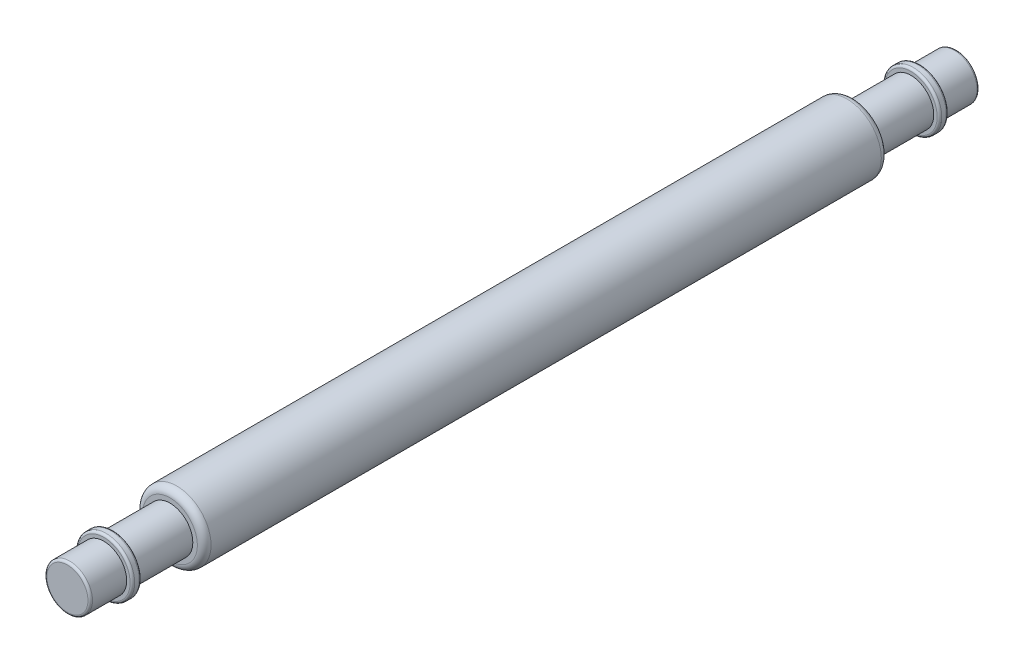
from build123d import *

# Parameters (mm, degrees)
SKETCH1_R            = 0.75
BOSS_EXTRUDE1_DEPTH  = 7.5
SKETCH2_R            = 0.5
BOSS_EXTRUDE2_DEPTH  = 9.75
FILLET1_R            = 0.15
FILLET2_R            = 0.05
BOSS_EXTRUDE3_START  = -0.8
SKETCH3_R            = 0.625
BOSS_EXTRUDE3_DEPTH  = 0.2
FILLET3_R            = 0.05
FILLET3_OF_MIRROR1_R = 0.05


with BuildPart() as part:
    # Sketch1 → Boss-Extrude1 (new body, symmetric)
    with BuildSketch(Plane.XY):
        Circle(SKETCH1_R)
    extrude(amount=BOSS_EXTRUDE1_DEPTH, both=True)

    # Sketch2 → Boss-Extrude2 (add, symmetric)
    with BuildSketch(Plane.XY):
        Circle(SKETCH2_R)
    extrude(amount=BOSS_EXTRUDE2_DEPTH, both=True)

    # Fillet1
    fillet1_edges = [part.edges().sort_by_distance(p)[0] for p in [
        (-0.75, 0, -7.5),
        (-0.75, 0, 7.5),
    ]]
    fillet(fillet1_edges, radius=FILLET1_R)

    # Fillet2
    fillet2_edges = [part.edges().sort_by_distance(p)[0] for p in [
        (-0.5, 0, -9.75),
        (-0.5, 0, 9.75),
    ]]
    fillet(fillet2_edges, radius=FILLET2_R)

    # Sketch3 → Boss-Extrude3 (add)
    with BuildSketch(Plane.XY.offset(9.75).offset(BOSS_EXTRUDE3_START)):
        Circle(SKETCH3_R)
    boss_extrude3 = extrude(amount=-BOSS_EXTRUDE3_DEPTH)

    # Fillet3
    fillet3_edges = [part.edges().sort_by_distance(p)[0] for p in [
        (-0.625, 0, 8.95),
        (-0.625, 0, 8.75),
    ]]
    fillet(fillet3_edges, radius=FILLET3_R)

    # Mirror1: Boss-Extrude3 across plane
    add(boss_extrude3.mirror(Plane.XY))

    # Fillet3 of Mirror1
    fillet3_of_mirror1_edges = [part.edges().sort_by_distance(p)[0] for p in [
        (-0.625, 0, -8.95),
        (-0.625, 0, -8.75),
    ]]
    fillet(fillet3_of_mirror1_edges, radius=FILLET3_OF_MIRROR1_R)


solid = part.part
